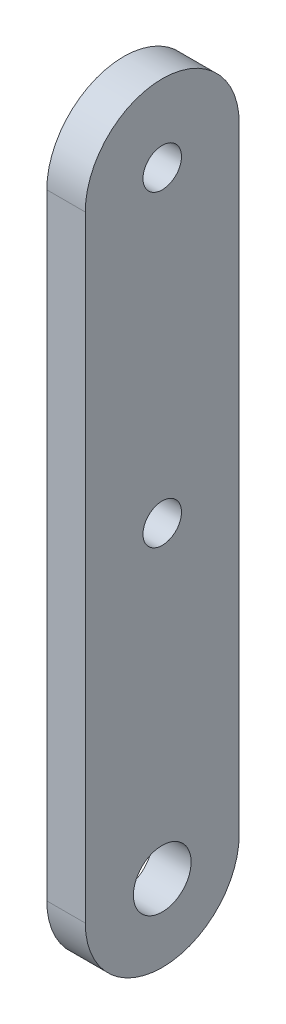
from build123d import *

# Parameters (mm, degrees)
SKETCH1_R           = 3.175
SKETCH1_R_2         = 4.7625
BOSS_EXTRUDE1_DEPTH = 6.35


with BuildPart() as part:
    # Sketch1 → Boss-Extrude1 (new body)
    with BuildSketch(Plane(origin=(0, 0, 0), x_dir=(0, 0, -1), z_dir=(1, 0, 0))):
        with BuildLine():
            Line((12.7, 50.8), (12.7, -50.8))
            ThreePointArc((12.7, -50.8), (0, -63.5), (-12.7, -50.8))
            Line((-12.7, -50.8), (-12.7, 50.8))
            ThreePointArc((-12.7, 50.8), (0, 63.5), (12.7, 50.8))
        make_face()
        with Locations((0, 50.8)):
            Circle(SKETCH1_R, mode=Mode.SUBTRACT)
        Circle(SKETCH1_R, mode=Mode.SUBTRACT)
        with Locations((0, -50.8)):
            Circle(SKETCH1_R_2, mode=Mode.SUBTRACT)
    extrude(amount=BOSS_EXTRUDE1_DEPTH)


solid = part.part
